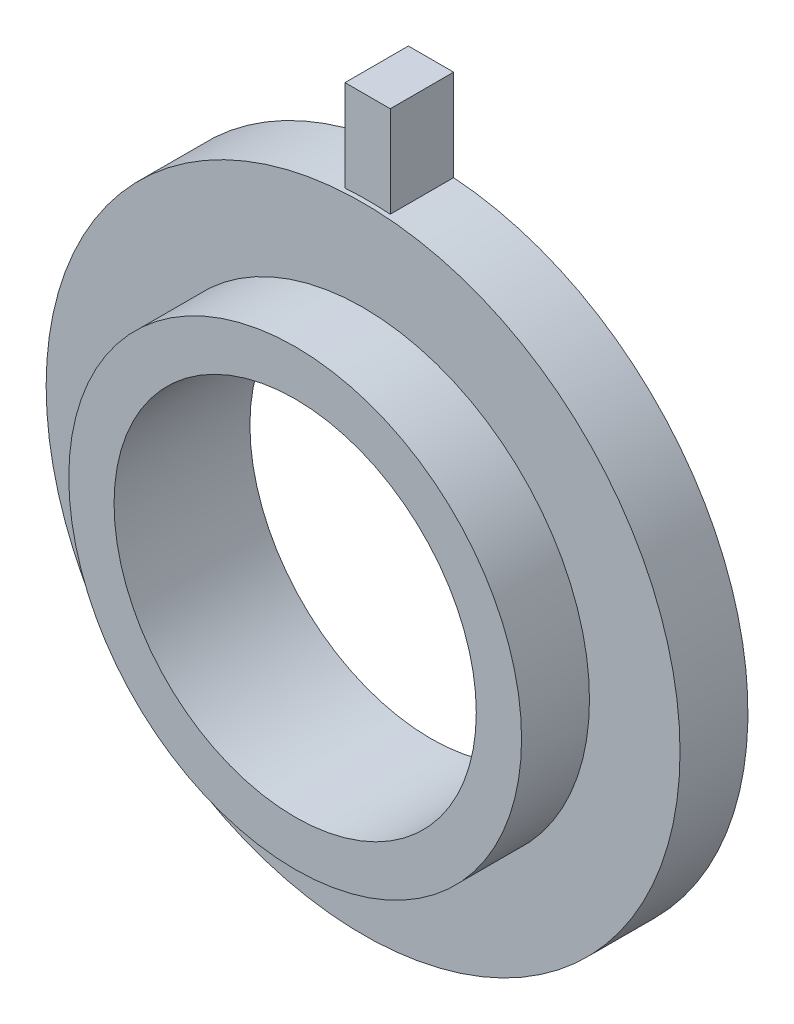
from build123d import *

# Parameters (mm, degrees)
SKETCH1_R           = 25
SKETCH1_R_2         = 20
BOSS_EXTRUDE1_DEPTH = 15
SKETCH2_R           = 35
SKETCH2_R_2         = 25
BOSS_EXTRUDE2_DEPTH = 7.5
SKETCH3_W           = 5
SKETCH3_H           = 16.794369207
BOSS_EXTRUDE3_DEPTH = 7


with BuildPart() as part:
    # Sketch1 → Boss-Extrude1 (new body)
    with BuildSketch(Plane.XY):
        Circle(SKETCH1_R)
        Circle(SKETCH1_R_2, mode=Mode.SUBTRACT)
    extrude(amount=BOSS_EXTRUDE1_DEPTH)

    # Sketch2 → Boss-Extrude2 (add)
    with BuildSketch(Plane(origin=(0, 0, 0), x_dir=(-1, 0, 0), z_dir=(0, 0, -1))):
        Circle(SKETCH2_R)
        Circle(SKETCH2_R_2, mode=Mode.SUBTRACT)
    extrude(amount=-BOSS_EXTRUDE2_DEPTH)

    # Sketch3 → Boss-Extrude3 (add)
    with BuildSketch(Plane.XY):
        with Locations((0, 36.602815396)):
            Rectangle(SKETCH3_W, SKETCH3_H)
    extrude(amount=BOSS_EXTRUDE3_DEPTH)


solid = part.part
